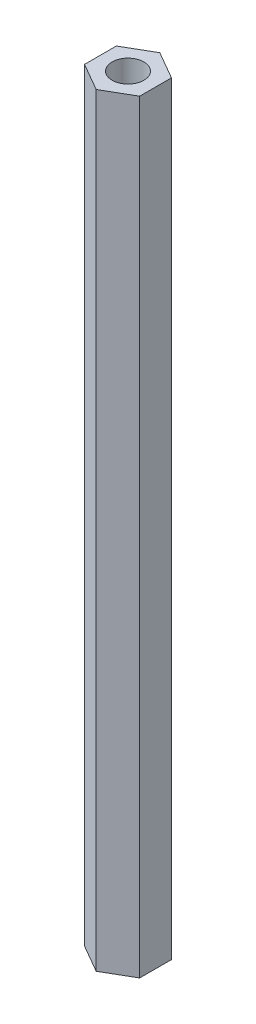
from build123d import *

# Parameters (mm, degrees)
ESQUISSE1_R      = 2.5
EXTRUSION1_DEPTH = 120


with BuildPart() as part:
    # Esquisse1 → Extrusion1 (new body)
    with BuildSketch(Plane(origin=(0, 0, 0), x_dir=(1, 0, 0), z_dir=(0, 1, 0))):
        Polygon((0, 5), (-4.330127019, 2.5), (-4.330127019, -2.5), (0, -5), (4.330127019, -2.5), (4.330127019, 2.5), align=None)
        Circle(ESQUISSE1_R, mode=Mode.SUBTRACT)
    extrude(amount=EXTRUSION1_DEPTH)


solid = part.part
